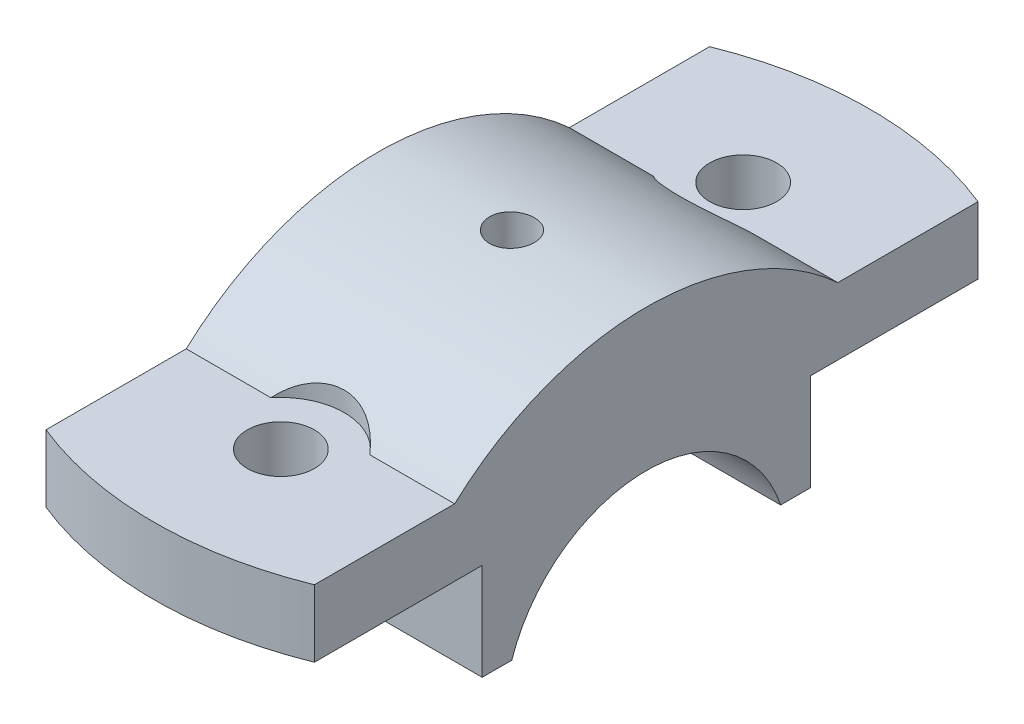
from build123d import *

# Parameters (mm, degrees)
BOSS_EXTRUDE4_DEPTH = 18
SKETCH5_R           = 4.5
CUT_EXTRUDE4_DEPTH  = 23
SKETCH7_R           = 8.5
CUT_EXTRUDE6_DEPTH  = 45
CUT_EXTRUDE7_DEPTH  = 45


with BuildPart() as part:
    # Sketch1 → Boss-Extrude4 (new body, symmetric)
    with BuildSketch(Plane(origin=(0, 0, 0), x_dir=(0, 0, -1), z_dir=(1, 0, 0))):
        with BuildLine():
            Line((22, 6), (22, 19))
            Line((22, 19), (50, 19))
            Line((50, 19), (50, 28))
            Line((50, 28), (25.690465157, 28))
            ThreePointArc((25.690465157, 28), (0, 38), (-25.690465157, 28))
            Line((-25.690465157, 28), (-50, 28))
            Line((-50, 28), (-50, 19))
            Line((-50, 19), (-22, 19))
            Line((-22, 19), (-22, 6))
            Line((-22, 6), (-18.027756377, 6))
            ThreePointArc((-18.027756377, 6), (0, 19), (18.027756377, 6))
            Line((18.027756377, 6), (22, 6))
        make_face()
    extrude(amount=BOSS_EXTRUDE4_DEPTH, both=True)

    # Sketch5 → Cut-Extrude4 (cut, through all)
    with BuildSketch(Plane(origin=(0, 28, 0), x_dir=(1, 0, 0), z_dir=(0, 1, 0))):
        with Locations(Location((0, 31, 0), (0, 0, 270))):  # turned: the seam where the file's is
            Circle(SKETCH5_R)
        with Locations(Location((0, -31, 0), (0, 0, 270))):  # turned: the seam where the file's is
            Circle(SKETCH5_R)
    extrude(amount=-CUT_EXTRUDE4_DEPTH, mode=Mode.SUBTRACT)

    # Sketch7 → Cut-Extrude6 (cut)
    with BuildSketch(Plane(origin=(0, 28, 0), x_dir=(1, 0, 0), z_dir=(0, 1, 0))):
        with Locations((0, -31)):
            Circle(SKETCH7_R)
        with Locations((0, 31)):
            Circle(SKETCH7_R)
    extrude(amount=CUT_EXTRUDE6_DEPTH, mode=Mode.SUBTRACT)

    # Sketch8 → Cut-Extrude7 (cut)
    with BuildSketch(Plane(origin=(0, 28, 0), x_dir=(1, 0, 0), z_dir=(0, 1, 0))):
        with BuildLine():
            Line((-18, -44.497190923), (-18, -50))
            Line((-18, -50), (18, -50))
            Line((18, -50), (18, -44.497190923))
            ThreePointArc((18, -44.497190923), (0, -48), (-18, -44.497190923))
        make_face()
        with BuildLine():
            Line((-18, 50), (-18, 44.497190923))
            ThreePointArc((-18, 44.497190923), (0, 48), (18, 44.497190923))
            Line((18, 44.497190923), (18, 50))
            Line((18, 50), (-18, 50))
        make_face()
    extrude(amount=-CUT_EXTRUDE7_DEPTH, mode=Mode.SUBTRACT)

    # Sketch11 → CBORE for M5 Hex Head Bolt2 (revolve, cut)
    with BuildSketch(Plane(origin=(0, 38, 0), x_dir=(0, 0, 1), z_dir=(1, 0, 0))):
        Polygon((0, 0), (0, 32), (2.5, 32), (2.5, 13.300129879), (2.9995, 13), (3, 0), align=None)
    revolve(axis=Axis((0, 44.35, 0), (0, -1, 0)), mode=Mode.SUBTRACT)


solid = part.part
